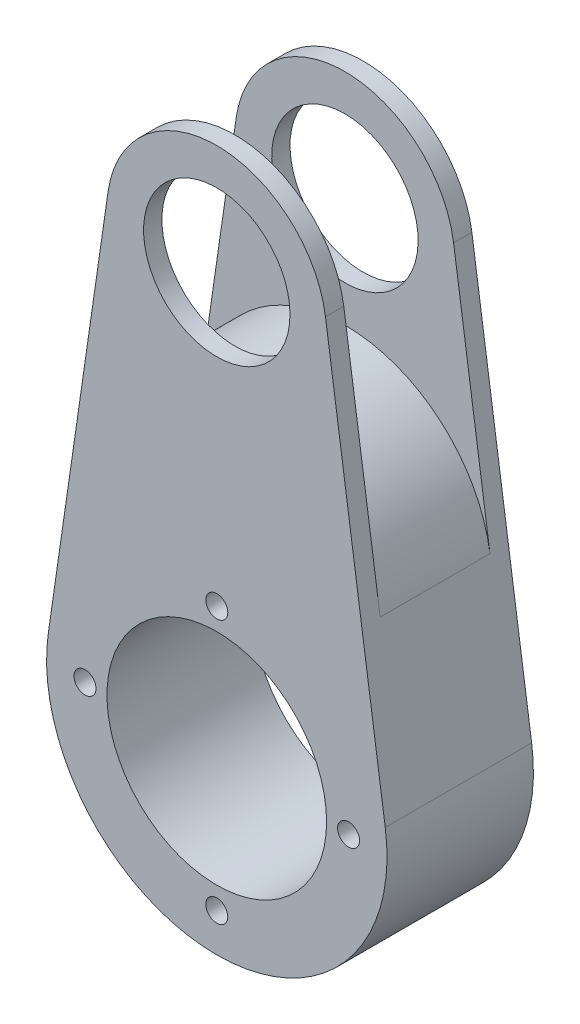
from build123d import *

# Parameters (mm, degrees)
CROQUIS1_R                 = 15
CROQUIS1_R_2               = 1.5
CROQUIS1_R_3               = 10
SALIENTE_EXTRUIR1_DEPTH    = 10
CORTAR_EXTRUIR2_DEPTH      = 24.25
CORTAR_EXTRUIR2_DEPTH_BACK = 24.25
REDONDEO3_R                = 20


with BuildPart() as part:
    # Croquis1 → Saliente-Extruir1 (new body, symmetric)
    with BuildSketch(Plane.XY):
        with BuildLine():
            Line((-23.009443154, 3.997898972), (-14.844802035, 60.31420332))
            ThreePointArc((-14.844802035, 60.31420332), (0, 73.162029407), (14.844802035, 60.31420332))
            Line((14.844802035, 60.31420332), (23.009443154, 3.997898972))
            ThreePointArc((23.009443154, 3.997898972), (0, -22.587970593), (-23.009443154, 3.997898972))
        make_face()
        with Locations((0, 0.662029407)):
            Circle(CROQUIS1_R, mode=Mode.SUBTRACT)
        with Locations((0, 18.662029407)):
            Circle(CROQUIS1_R_2, mode=Mode.SUBTRACT)
        with Locations((18, 0.662029407)):
            Circle(CROQUIS1_R_2, mode=Mode.SUBTRACT)
        with Locations((0, -17.337970593)):
            Circle(CROQUIS1_R_2, mode=Mode.SUBTRACT)
        with Locations((-18, 0.662029407)):
            Circle(CROQUIS1_R_2, mode=Mode.SUBTRACT)
        with Locations((0, 58.162029407)):
            Circle(CROQUIS1_R_3, mode=Mode.SUBTRACT)
    extrude(amount=SALIENTE_EXTRUIR1_DEPTH, both=True)

    # Croquis3 → Cortar-Extruir2 (cut, two sides)
    with BuildSketch(Plane(origin=(0, 0, 0), x_dir=(0, 0, -1), z_dir=(1, 0, 0))) as cortar_extruir2_sk:
        Polygon((0, 73.162029407), (7.5, 73.162029407), (7.5, 43.162029407), (-7.5, 43.162029407), (-7.5, 73.162029407), align=None)
    extrude(amount=CORTAR_EXTRUIR2_DEPTH, mode=Mode.SUBTRACT)
    extrude(cortar_extruir2_sk.sketch, amount=-CORTAR_EXTRUIR2_DEPTH_BACK, mode=Mode.SUBTRACT)

    # Redondeo3
    redondeo3_edges = [part.edges().sort_by_distance(p)[0] for p in [
        (-17.331494761, 43.162029407, 0),
        (17.331494761, 43.162029407, 0),
    ]]
    fillet(redondeo3_edges, radius=REDONDEO3_R)


solid = part.part
